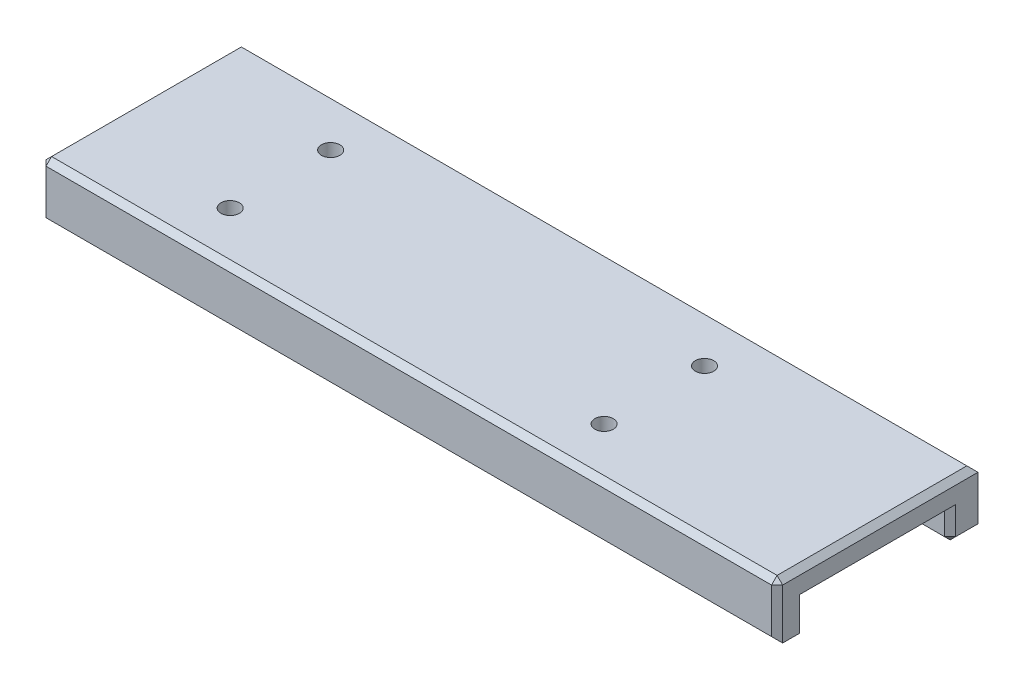
from build123d import *

# Parameters (mm, degrees)
SKETCH1_W                       = 132
SKETCH1_H                       = 36
BOSS_EXTRUDE1_DEPTH             = 5
SKETCH2_W                       = 26
SKETCH2_H                       = 5
CUT_EXTRUDE1_DEPTH              = 67
CUT_EXTRUDE1_DEPTH_BACK         = 67
CHAMFER1_SIZE                   = 1
TAP_DRILL_FOR_M4X0_7_TAP1_D     = 3.3
TAP_DRILL_FOR_M4X0_7_TAP1_DEPTH = 14
TAP_DRILL_FOR_M4X0_7_TAP1_TIP   = 0.991420021


with BuildPart() as part:
    # Sketch1 → Boss-Extrude1 (new body, symmetric)
    with BuildSketch(Plane(origin=(0, 0, 0), x_dir=(1, 0, 0), z_dir=(0, 1, 0))):
        Rectangle(SKETCH1_W, SKETCH1_H)
    extrude(amount=BOSS_EXTRUDE1_DEPTH, both=True)

    # Sketch2 → Cut-Extrude1 (cut, two sides)
    with BuildSketch(Plane(origin=(0, 0, 0), x_dir=(0, 0, -1), z_dir=(1, 0, 0))) as cut_extrude1_sk:
        with Locations((0, -2.5)):
            Rectangle(SKETCH2_W, SKETCH2_H)
    extrude(amount=CUT_EXTRUDE1_DEPTH, mode=Mode.SUBTRACT)
    extrude(cut_extrude1_sk.sketch, amount=-CUT_EXTRUDE1_DEPTH_BACK, mode=Mode.SUBTRACT)

    # Chamfer1
    chamfer1_edges = [part.edges().sort_by_distance(p)[0] for p in [
        (-66, -2.5, 13),
        (-66, -5, -15.5),
        (-66, 0, 0),
        (-66, -2.5, -13),
        (0, -5, 13),
        (66, -5, -15.5),
        (66, -2.5, -13),
        (66, 0, 0),
        (66, -2.5, 13),
        (0, -5, 18),
        (66, 0, 18),
        (66, 5, 0),
        (0, 5, -18),
        (-66, 5, 0),
        (0, 5, 18),
        (-66, 0, 18),
        (0, -5, -13),
    ]]
    chamfer(chamfer1_edges, length=CHAMFER1_SIZE)

    # Tap Drill for M4x0.7 Tap1
    with Locations(Plane(origin=(-96, 5, 18), x_dir=(1, 0, 0), z_dir=(0, 1, 0))):
        with Locations((55, 27), (122, 27), (55, 9), (122, 9)):
            Hole(TAP_DRILL_FOR_M4X0_7_TAP1_D / 2, depth=TAP_DRILL_FOR_M4X0_7_TAP1_DEPTH)
            with Locations((0, 0, -(TAP_DRILL_FOR_M4X0_7_TAP1_DEPTH + TAP_DRILL_FOR_M4X0_7_TAP1_TIP / 2))):  # 118° drill point
                Cone(0, TAP_DRILL_FOR_M4X0_7_TAP1_D / 2, TAP_DRILL_FOR_M4X0_7_TAP1_TIP, mode=Mode.SUBTRACT)


solid = part.part
